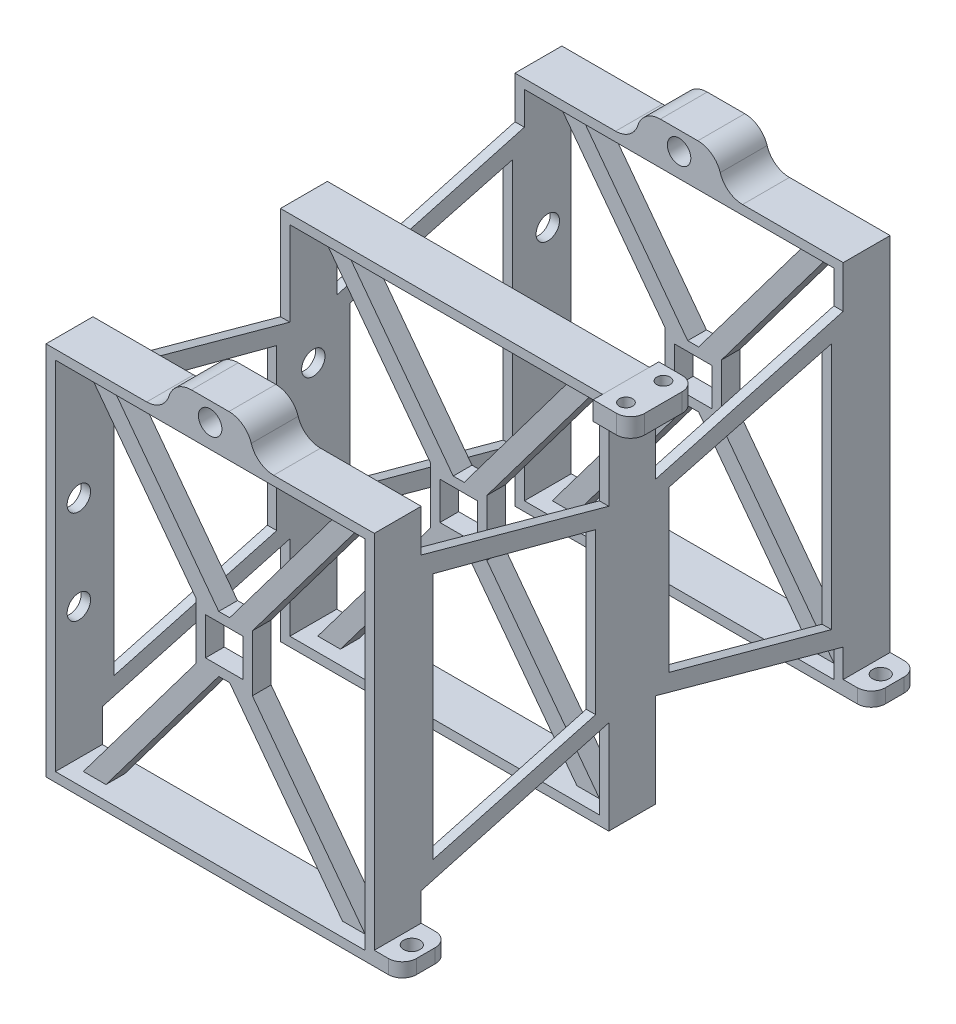
from build123d import *

# Parameters (mm, degrees)
SKETCH2_W                = 70
SKETCH2_H                = 80
SKETCH2_W_2              = 66
SKETCH2_H_2              = 76
BOSS_EXTRUDE1_DEPTH      = 5
BOSS_EXTRUDE1_DEPTH_BACK = 5
BOSS_EXTRUDE2_DEPTH      = 2
BOSS_EXTRUDE2_DEPTH_BACK = 2
SKETCH3_4_W              = 12
SKETCH3_4_H              = 12
SKETCH3_4_W_2            = 8
SKETCH3_4_H_2            = 8
BOSS_EXTRUDE3_DEPTH      = 2
BOSS_EXTRUDE3_DEPTH_BACK = 2
LPATTERN1_COUNT          = 2
LPATTERN1_PITCH          = 50
BOSS_EXTRUDE4_DEPTH      = 0.0001
BOSS_EXTRUDE4_DEPTH_BACK = 4
FILLET1_R                = 3
SKETCH5_R                = 1.413098434
SKETCH5_R_2              = 1.415
CUT_EXTRUDE1_DEPTH       = 17.0001
SKETCH9_W                = 6
SKETCH9_H                = 10
BOSS_EXTRUDE7_DEPTH      = 3
SKETCH10_R               = 1.750691526
CUT_EXTRUDE3_DEPTH       = 22
FILLET3_R                = 3
SKETCH11_W               = 18
SKETCH11_H               = 10
BOSS_EXTRUDE8_DEPTH      = 7
FILLET5_R                = 5
SKETCH12_R               = 2.5
CUT_EXTRUDE4_DEPTH       = 20
FILLET6_R                = 5
SKETCH13_R               = 2.5
CUT_EXTRUDE5_DEPTH       = 20
SKETCH14_W               = 2
SKETCH14_H               = 72
BOSS_EXTRUDE9_DEPTH      = 40
CUT_EXTRUDE6_DEPTH       = 20
CUT_EXTRUDE6_DEPTH_BACK  = 77.663032723
BOSS_EXTRUDE10_START     = -50
SKETCH16_W               = 2
SKETCH16_H               = 70
BOSS_EXTRUDE10_DEPTH     = 90
BOSS_EXTRUDE11_REACH     = 52
SKETCH17_W               = 2
SKETCH17_H               = 70
CUT_EXTRUDE7_DEPTH       = 20
CUT_EXTRUDE7_DEPTH_BACK  = 20
CUT_EXTRUDE8_DEPTH       = 20
CUT_EXTRUDE8_DEPTH_BACK  = 77.663032723


with BuildPart() as part:
    # Sketch2 → Boss-Extrude1 (new body, two sides)
    with BuildSketch(Plane.XY) as boss_extrude1_sk:
        Rectangle(SKETCH2_W, SKETCH2_H)
        Rectangle(SKETCH2_W_2, SKETCH2_H_2, mode=Mode.SUBTRACT)
    extrude(amount=BOSS_EXTRUDE1_DEPTH)
    extrude(boss_extrude1_sk.sketch, amount=-BOSS_EXTRUDE1_DEPTH_BACK)

    # Sketch3 → Boss-Extrude2 (add, two sides)
    with BuildSketch(Plane.XY) as boss_extrude2_sk:
        Polygon((-1.167512875, 6), (-6, 6), (-30.04616475, 38), (-25.213677625, 38), align=None)
    extrude(amount=BOSS_EXTRUDE2_DEPTH)
    extrude(boss_extrude2_sk.sketch, amount=-BOSS_EXTRUDE2_DEPTH_BACK)

    # Sketch3_4 → Boss-Extrude3 (add, two sides)
    with BuildSketch(Plane.XY) as boss_extrude3_sk:
        Polygon((25.213677625, 38), (1.167512875, 6), (6, 6), (30.04616475, 38), align=None)
        Rectangle(SKETCH3_4_W, SKETCH3_4_H)
        Rectangle(SKETCH3_4_W_2, SKETCH3_4_H_2, mode=Mode.SUBTRACT)
        Polygon((6, -6), (1.167512875, -6), (25.213677625, -38), (30.04616475, -38), align=None)
        Polygon((-1.167512875, -6), (-6, -6), (-30.04616475, -38), (-25.213677625, -38), align=None)
    extrude(amount=BOSS_EXTRUDE3_DEPTH)
    extrude(boss_extrude3_sk.sketch, amount=-BOSS_EXTRUDE3_DEPTH_BACK)


with BuildPart() as lpattern1_1:
    # LPattern1: pattern copy
    add(part.part.moved(Location(Vector(0, 0, -1) * (1 * LPATTERN1_PITCH))))

    # Sketch9 → Boss-Extrude7 (add)
    with BuildSketch(Plane.XZ.offset(40)):
        with Locations((38, -50)):
            Rectangle(SKETCH9_W, SKETCH9_H)
    extrude(amount=-BOSS_EXTRUDE7_DEPTH)

    # Sketch10 → Cut-Extrude3 (cut)
    with BuildSketch(Plane.XZ.offset(40)):
        with Locations((38, -50)):
            Circle(SKETCH10_R)
    extrude(amount=-CUT_EXTRUDE3_DEPTH, mode=Mode.SUBTRACT)

    # Fillet3
    fillet3_edges = [lpattern1_1.edges().sort_by_distance(p)[0] for p in [
        (41, -38.5, -45),
        (41, -38.5, -55),
    ]]
    fillet(fillet3_edges, radius=FILLET3_R)

    # Sketch11 → Boss-Extrude8 (add)
    with BuildSketch(Plane(origin=(0, 40, 0), x_dir=(1, 0, 0), z_dir=(0, 1, 0))):
        with Locations((0, 50)):
            Rectangle(SKETCH11_W, SKETCH11_H)
    extrude(amount=BOSS_EXTRUDE8_DEPTH)

    # Fillet5
    fillet5_edges = [lpattern1_1.edges().sort_by_distance(p)[0] for p in [
        (-9, 47, -50),
        (9, 47, -50),
    ]]
    fillet(fillet5_edges, radius=FILLET5_R)

    # Sketch12 → Cut-Extrude4 (cut)
    with BuildSketch(Plane.XY.offset(-45)):
        with Locations((0, 43)):
            Circle(SKETCH12_R)
    extrude(amount=-CUT_EXTRUDE4_DEPTH, mode=Mode.SUBTRACT)

    # Fillet6
    fillet6_edges = [lpattern1_1.edges().sort_by_distance(p)[0] for p in [
        (-9, 40, -50),
        (9, 40, -50),
    ]]
    fillet(fillet6_edges, radius=FILLET6_R)


with BuildPart() as part_1:
    add(part.part)

    # Sketch4 → Boss-Extrude4 (add, two sides)
    with BuildSketch(Plane(origin=(0, 40, 0), x_dir=(1, 0, 0), z_dir=(0, 1, 0))) as boss_extrude4_sk:
        Polygon((33.663032723, 5), (33.663032723, 7), (41.663032723, 7), (41.663032723, -7), (33.663032723, -7), align=None)
    extrude(amount=BOSS_EXTRUDE4_DEPTH)
    extrude(boss_extrude4_sk.sketch, amount=-BOSS_EXTRUDE4_DEPTH_BACK)

    # Fillet1
    fillet1_edges = [part_1.edges().sort_by_distance(p)[0] for p in [
        (41.663032723, 38.00005, -7),
        (41.663032723, 38.00005, 7),
    ]]
    fillet(fillet1_edges, radius=FILLET1_R)

    # Sketch5 → Cut-Extrude1 (cut)
    with BuildSketch(Plane(origin=(0, 40.0001, 0), x_dir=(1, 0, 0), z_dir=(0, 1, 0))):
        with Locations((37.663032723, 4)):
            Circle(SKETCH5_R)
        with Locations((37.663032723, -4)):
            Circle(SKETCH5_R_2)
    extrude(amount=-CUT_EXTRUDE1_DEPTH, mode=Mode.SUBTRACT)


with BuildPart() as cut_extrude5_tool:
    # Sketch13 → Cut-Extrude5 (new body)
    with BuildSketch(Plane.ZY.offset(35)):
        with Locations((-50, 10)):
            Circle(SKETCH13_R)
        with Locations((-50, -10)):
            Circle(SKETCH13_R)
        with Locations((0, 10)):
            Circle(SKETCH13_R)
        with Locations((0, -10)):
            Circle(SKETCH13_R)
    extrude(amount=-CUT_EXTRUDE5_DEPTH)


with BuildPart() as part_2:
    add(part_1.part)

    # Cut-Extrude5: cut by cut_extrude5_tool
    add(cut_extrude5_tool.part, mode=Mode.SUBTRACT)



with BuildPart() as lpattern1_1_1:
    add(lpattern1_1.part)

    # Cut-Extrude5: cut by cut_extrude5_tool
    add(cut_extrude5_tool.part, mode=Mode.SUBTRACT)


with BuildPart() as body_3:
    # Mirror1: mirrored copy
    add(lpattern1_1_1.part.mirror(Plane.XY))


with BuildPart() as part_3:
    add(part_2.part)

    add(lpattern1_1_1.part)  # Boss-Extrude9 merges LPattern1_1
    # Sketch14 → Boss-Extrude9 (add)
    with BuildSketch(Plane(origin=(0, 0, -5), x_dir=(-1, 0, 0), z_dir=(0, 0, -1))):
        with Locations((34, 0)):
            Rectangle(SKETCH14_W, SKETCH14_H)
    extrude(amount=BOSS_EXTRUDE9_DEPTH)

    # Sketch15 → Cut-Extrude6 (cut, two sides)
    with BuildSketch(Plane.ZY.offset(35)) as cut_extrude6_sk:
        Polygon((-45, 36), (-45, 31), (-5, 20), (-5, 36), align=None)
        Polygon((-45, -36), (-45, -31), (-5, -20), (-5, -36), align=None)
        Polygon((-42.5, 26.274386076), (-7.8, 17.089091958), (-7.8, -17.089296519), (-42.5, -26.526057423), align=None)
        Polygon((5, -20), (5, -36), (45, -36), (45, -31), align=None)
        Polygon((7.8, -17.089296519), (42.5, -26.526057423), (42.5, 26.274386076), (7.8, 17.089091958), align=None)
        Polygon((5, 20), (5, 36), (45, 36), (45, 31), align=None)
    extrude(amount=CUT_EXTRUDE6_DEPTH, mode=Mode.SUBTRACT)
    extrude(cut_extrude6_sk.sketch, amount=-CUT_EXTRUDE6_DEPTH_BACK, mode=Mode.SUBTRACT)


    add(body_3.part)  # Boss-Extrude10 merges body 3
    # Sketch16 → Boss-Extrude10 (add)
    with BuildSketch(Plane(origin=(0, 0, -5), x_dir=(-1, 0, 0), z_dir=(0, 0, -1)).offset(BOSS_EXTRUDE10_START)):
        with Locations((-34, 0)):
            Rectangle(SKETCH16_W, SKETCH16_H)
    extrude(amount=BOSS_EXTRUDE10_DEPTH)

    # Sketch17 → Boss-Extrude11 (add, up to next)
    with BuildSketch(Plane.XY.offset(5), mode=Mode.PRIVATE) as boss_extrude11_sk1:
        with Locations((-34, 0)):
            Rectangle(SKETCH17_W, SKETCH17_H)
    boss_extrude11_tool1 = extrude(boss_extrude11_sk1.sketch, amount=BOSS_EXTRUDE11_REACH, mode=Mode.PRIVATE) - part_3.part
    add(boss_extrude11_tool1.solids().sort_by_distance((-34, 0, 5))[0])

    # Sketch18 → Cut-Extrude7 (cut, two sides)
    with BuildSketch(Plane(origin=(35, 0, 0), x_dir=(0, 0, -1), z_dir=(1, 0, 0))) as cut_extrude7_sk:
        Polygon((45, -36), (45, -31), (5, -20), (5, -36), align=None)
        Polygon((45, 31), (45, 36), (5, 36), (5, 20), align=None)
        Polygon((7.8, 17.089091958), (7.8, -17.089296519), (42.5, -26.526057423), (42.5, 26.274386076), align=None)
    extrude(amount=CUT_EXTRUDE7_DEPTH, mode=Mode.SUBTRACT)
    extrude(cut_extrude7_sk.sketch, amount=-CUT_EXTRUDE7_DEPTH_BACK, mode=Mode.SUBTRACT)

    # Sketch19 → Cut-Extrude8 (cut, two sides)
    with BuildSketch(Plane.ZY.offset(35)) as cut_extrude8_sk:
        Polygon((-45, -31), (-45, -36), (-5, -36), (-5, -20), align=None)
        Polygon((-45, 36), (-45, 31), (-5, 20), (-5, 36), align=None)
        Polygon((5, -20), (5, -36), (45, -36), (45, -31), align=None)
        Polygon((-7.8, -17.089296519), (-7.8, 17.089091958), (-42.5, 26.274386076), (-42.5, -26.526057423), align=None)
        Polygon((5, 36), (5, 20), (45, 31), (45, 36), align=None)
        Polygon((42.5, 26.274386076), (7.8, 17.089091958), (7.8, -17.089296519), (42.5, -26.526057423), align=None)
    extrude(amount=CUT_EXTRUDE8_DEPTH, mode=Mode.SUBTRACT)
    extrude(cut_extrude8_sk.sketch, amount=-CUT_EXTRUDE8_DEPTH_BACK, mode=Mode.SUBTRACT)


solid = part_3.part
